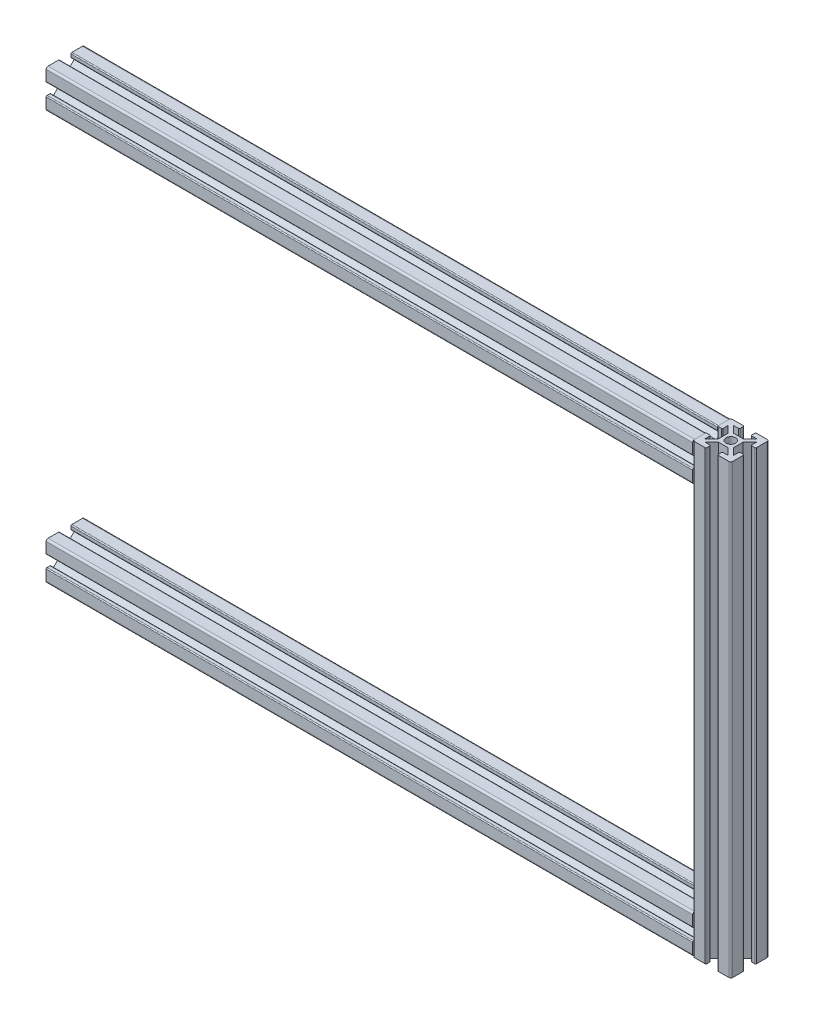
from build123d import *

# Parameters (mm, degrees)
SKETCH1_R                               = 2.5
ALUMINIUM_PROF_ALUMINIUM_PROF_1_DEPTH   = 365.192388155
SKETCH1_ON_SEGMENT_2_R                  = 2.5
ALUMINIUM_PROF_ALUMINIUM_PROF_1_2_DEPTH = 245.384776311
SKETCH1_ON_SEGMENT_3_R                  = 2.5
ALUMINIUM_PROF_ALUMINIUM_PROF_1_3_DEPTH = 365.192388155
BODY_START                              = 61.926406871
BODY_2_RUN_ON_DEPTH                     = 57.269552622
BODY_START_2                            = 183.458369439
BODY_2_RUN_ON_2_DEPTH                   = 57.269552622
SKETCH3_R                               = 2.5
CUT_EXTRUDE1_DEPTH                      = 10


with BuildPart() as part:
    # Sketch1 → Aluminium prof ALUMINIUM PROF(1) (new body)
    with BuildSketch(Plane.YZ):
        with BuildLine():
            Line((-2.5, 4), (2.5, 4))
            Line((2.5, 4), (6.035533906, 7.535533906))
            Line((6.035533906, 7.535533906), (3.535533906, 7.535533906))
            ThreePointArc((3.535533906, 7.535533906), (3.181980515, 7.681980515), (3.035533906, 8.035533906))
            Line((3.035533906, 8.035533906), (3.035533906, 9.535533906))
            ThreePointArc((3.035533906, 9.535533906), (3.181980515, 9.889087297), (3.535533906, 10.035533906))
            Line((3.535533906, 10.035533906), (9.035533906, 10.035533906))
            ThreePointArc((9.035533906, 10.035533906), (9.742640687, 9.742640687), (10.035533906, 9.035533906))
            Line((10.035533906, 9.035533906), (10.035533906, 3.535533906))
            ThreePointArc((10.035533906, 3.535533906), (9.889087297, 3.181980515), (9.535533906, 3.035533906))
            Line((9.535533906, 3.035533906), (8.035533906, 3.035533906))
            ThreePointArc((8.035533906, 3.035533906), (7.681980515, 3.181980515), (7.535533906, 3.535533906))
            Line((7.535533906, 3.535533906), (7.535533906, 6.035533906))
            Line((7.535533906, 6.035533906), (4, 2.5))
            Line((4, 2.5), (4, -2.5))
            Line((4, -2.5), (7.535533906, -6.035533906))
            Line((7.535533906, -6.035533906), (7.535533906, -3.535533906))
            ThreePointArc((7.535533906, -3.535533906), (7.681980515, -3.181980515), (8.035533906, -3.035533906))
            Line((8.035533906, -3.035533906), (9.535533906, -3.035533906))
            ThreePointArc((9.535533906, -3.035533906), (9.889087297, -3.181980515), (10.035533906, -3.535533906))
            Line((10.035533906, -3.535533906), (10.035533906, -9.035533906))
            ThreePointArc((10.035533906, -9.035533906), (9.742640687, -9.742640687), (9.035533906, -10.035533906))
            Line((9.035533906, -10.035533906), (3.535533906, -10.035533906))
            ThreePointArc((3.535533906, -10.035533906), (3.181980515, -9.889087297), (3.035533906, -9.535533906))
            Line((3.035533906, -9.535533906), (3.035533906, -8.035533906))
            ThreePointArc((3.035533906, -8.035533906), (3.181980515, -7.681980515), (3.535533906, -7.535533906))
            Line((3.535533906, -7.535533906), (6.035533906, -7.535533906))
            Line((6.035533906, -7.535533906), (2.5, -4))
            Line((2.5, -4), (-2.5, -4))
            Line((-2.5, -4), (-6.035533906, -7.535533906))
            Line((-6.035533906, -7.535533906), (-3.535533906, -7.535533906))
            ThreePointArc((-3.535533906, -7.535533906), (-3.181980515, -7.681980515), (-3.035533906, -8.035533906))
            Line((-3.035533906, -8.035533906), (-3.035533906, -9.535533906))
            ThreePointArc((-3.035533906, -9.535533906), (-3.181980515, -9.889087297), (-3.535533906, -10.035533906))
            Line((-3.535533906, -10.035533906), (-9.035533906, -10.035533906))
            ThreePointArc((-9.035533906, -10.035533906), (-9.742640687, -9.742640687), (-10.035533906, -9.035533906))
            Line((-10.035533906, -9.035533906), (-10.035533906, -3.535533906))
            ThreePointArc((-10.035533906, -3.535533906), (-9.889087297, -3.181980515), (-9.535533906, -3.035533906))
            Line((-9.535533906, -3.035533906), (-8.035533906, -3.035533906))
            ThreePointArc((-8.035533906, -3.035533906), (-7.681980515, -3.181980515), (-7.535533906, -3.535533906))
            Line((-7.535533906, -3.535533906), (-7.535533906, -6.035533906))
            Line((-7.535533906, -6.035533906), (-4, -2.5))
            Line((-4, -2.5), (-4, 2.5))
            Line((-4, 2.5), (-7.535533906, 6.035533906))
            Line((-7.535533906, 6.035533906), (-7.535533906, 3.535533906))
            ThreePointArc((-7.535533906, 3.535533906), (-7.681980515, 3.181980515), (-8.035533906, 3.035533906))
            Line((-8.035533906, 3.035533906), (-9.535533906, 3.035533906))
            ThreePointArc((-9.535533906, 3.035533906), (-9.889087297, 3.181980515), (-10.035533906, 3.535533906))
            Line((-10.035533906, 3.535533906), (-10.035533906, 9.035533906))
            ThreePointArc((-10.035533906, 9.035533906), (-9.742640687, 9.742640687), (-9.035533906, 10.035533906))
            Line((-9.035533906, 10.035533906), (-3.535533906, 10.035533906))
            ThreePointArc((-3.535533906, 10.035533906), (-3.181980515, 9.889087297), (-3.035533906, 9.535533906))
            Line((-3.035533906, 9.535533906), (-3.035533906, 8.035533906))
            ThreePointArc((-3.035533906, 8.035533906), (-3.181980515, 7.681980515), (-3.535533906, 7.535533906))
            Line((-3.535533906, 7.535533906), (-6.035533906, 7.535533906))
            Line((-6.035533906, 7.535533906), (-2.5, 4))
        make_face()
        Circle(SKETCH1_R, mode=Mode.SUBTRACT)
    extrude(amount=ALUMINIUM_PROF_ALUMINIUM_PROF_1_DEPTH)

    # Aluminium prof ALUMINIUM PROF(1) mitre 1
    split(bisect_by=Plane(origin=(350, 0, 0), x_dir=(-0.707106781, -0.707106781, 0), z_dir=(-0.707106781, 0.707106781, 0)), keep=Keep.TOP)

    # Trim_Extend1 8
    split(bisect_by=Plane(origin=(355.77696345, -107.5, 4.27696345), x_dir=(0, -1, 0), z_dir=(-0.707106781, 0, 0.707106781)), keep=Keep.TOP)

    # Trim_Extend1 10
    split(bisect_by=Plane(origin=(355.77696345, -107.5, -4.27696345), x_dir=(0, -1, 0), z_dir=(-0.707106781, 0, -0.707106781)), keep=Keep.TOP)

    # Trim_Extend1 21
    split(bisect_by=Plane(origin=(339.964466094, -107.5, 6.285533906), x_dir=(0, -1, 0), z_dir=(-1, 0, 0)), keep=Keep.TOP)

    # Sketch3 → Cut-Extrude1 (cut)
    with BuildSketch(Plane(origin=(0, 4, 0), x_dir=(1, 0, 0), z_dir=(0, 1, 0))):
        with Locations(Location((75, 0, 0), (0, 0, 270))):
            Circle(SKETCH3_R)
        with Locations(Location((175, 0, 0), (0, 0, 270))):
            Circle(SKETCH3_R)
        with Locations(Location((264.964466094, 0, 0), (0, 0, 270))):
            Circle(SKETCH3_R)
    extrude(amount=-CUT_EXTRUDE1_DEPTH, mode=Mode.SUBTRACT)


with BuildPart() as body_2:
    # Sketch1 on segment 2 (carried to segment 2) → Aluminium prof ALUMINIUM PROF_1 2 (new body)
    with BuildSketch(Plane(origin=(350, 15.192388155, 0), x_dir=(1, 0, 0), z_dir=(0, -1, 0))):
        with BuildLine():
            Line((-2.5, 4), (2.5, 4))
            Line((2.5, 4), (6.035533906, 7.535533906))
            Line((6.035533906, 7.535533906), (3.535533906, 7.535533906))
            ThreePointArc((3.535533906, 7.535533906), (3.181980515, 7.681980515), (3.035533906, 8.035533906))
            Line((3.035533906, 8.035533906), (3.035533906, 9.535533906))
            ThreePointArc((3.035533906, 9.535533906), (3.181980515, 9.889087297), (3.535533906, 10.035533906))
            Line((3.535533906, 10.035533906), (9.035533906, 10.035533906))
            ThreePointArc((9.035533906, 10.035533906), (9.742640687, 9.742640687), (10.035533906, 9.035533906))
            Line((10.035533906, 9.035533906), (10.035533906, 3.535533906))
            ThreePointArc((10.035533906, 3.535533906), (9.889087297, 3.181980515), (9.535533906, 3.035533906))
            Line((9.535533906, 3.035533906), (8.035533906, 3.035533906))
            ThreePointArc((8.035533906, 3.035533906), (7.681980515, 3.181980515), (7.535533906, 3.535533906))
            Line((7.535533906, 3.535533906), (7.535533906, 6.035533906))
            Line((7.535533906, 6.035533906), (4, 2.5))
            Line((4, 2.5), (4, -2.5))
            Line((4, -2.5), (7.535533906, -6.035533906))
            Line((7.535533906, -6.035533906), (7.535533906, -3.535533906))
            ThreePointArc((7.535533906, -3.535533906), (7.681980515, -3.181980515), (8.035533906, -3.035533906))
            Line((8.035533906, -3.035533906), (9.535533906, -3.035533906))
            ThreePointArc((9.535533906, -3.035533906), (9.889087297, -3.181980515), (10.035533906, -3.535533906))
            Line((10.035533906, -3.535533906), (10.035533906, -9.035533906))
            ThreePointArc((10.035533906, -9.035533906), (9.742640687, -9.742640687), (9.035533906, -10.035533906))
            Line((9.035533906, -10.035533906), (3.535533906, -10.035533906))
            ThreePointArc((3.535533906, -10.035533906), (3.181980515, -9.889087297), (3.035533906, -9.535533906))
            Line((3.035533906, -9.535533906), (3.035533906, -8.035533906))
            ThreePointArc((3.035533906, -8.035533906), (3.181980515, -7.681980515), (3.535533906, -7.535533906))
            Line((3.535533906, -7.535533906), (6.035533906, -7.535533906))
            Line((6.035533906, -7.535533906), (2.5, -4))
            Line((2.5, -4), (-2.5, -4))
            Line((-2.5, -4), (-6.035533906, -7.535533906))
            Line((-6.035533906, -7.535533906), (-3.535533906, -7.535533906))
            ThreePointArc((-3.535533906, -7.535533906), (-3.181980515, -7.681980515), (-3.035533906, -8.035533906))
            Line((-3.035533906, -8.035533906), (-3.035533906, -9.535533906))
            ThreePointArc((-3.035533906, -9.535533906), (-3.181980515, -9.889087297), (-3.535533906, -10.035533906))
            Line((-3.535533906, -10.035533906), (-9.035533906, -10.035533906))
            ThreePointArc((-9.035533906, -10.035533906), (-9.742640687, -9.742640687), (-10.035533906, -9.035533906))
            Line((-10.035533906, -9.035533906), (-10.035533906, -3.535533906))
            ThreePointArc((-10.035533906, -3.535533906), (-9.889087297, -3.181980515), (-9.535533906, -3.035533906))
            Line((-9.535533906, -3.035533906), (-8.035533906, -3.035533906))
            ThreePointArc((-8.035533906, -3.035533906), (-7.681980515, -3.181980515), (-7.535533906, -3.535533906))
            Line((-7.535533906, -3.535533906), (-7.535533906, -6.035533906))
            Line((-7.535533906, -6.035533906), (-4, -2.5))
            Line((-4, -2.5), (-4, 2.5))
            Line((-4, 2.5), (-7.535533906, 6.035533906))
            Line((-7.535533906, 6.035533906), (-7.535533906, 3.535533906))
            ThreePointArc((-7.535533906, 3.535533906), (-7.681980515, 3.181980515), (-8.035533906, 3.035533906))
            Line((-8.035533906, 3.035533906), (-9.535533906, 3.035533906))
            ThreePointArc((-9.535533906, 3.035533906), (-9.889087297, 3.181980515), (-10.035533906, 3.535533906))
            Line((-10.035533906, 3.535533906), (-10.035533906, 9.035533906))
            ThreePointArc((-10.035533906, 9.035533906), (-9.742640687, 9.742640687), (-9.035533906, 10.035533906))
            Line((-9.035533906, 10.035533906), (-3.535533906, 10.035533906))
            ThreePointArc((-3.535533906, 10.035533906), (-3.181980515, 9.889087297), (-3.035533906, 9.535533906))
            Line((-3.035533906, 9.535533906), (-3.035533906, 8.035533906))
            ThreePointArc((-3.035533906, 8.035533906), (-3.181980515, 7.681980515), (-3.535533906, 7.535533906))
            Line((-3.535533906, 7.535533906), (-6.035533906, 7.535533906))
            Line((-6.035533906, 7.535533906), (-2.5, 4))
        make_face()
        Circle(SKETCH1_ON_SEGMENT_2_R, mode=Mode.SUBTRACT)
    extrude(amount=ALUMINIUM_PROF_ALUMINIUM_PROF_1_2_DEPTH)

    # Aluminium prof ALUMINIUM PROF_1 2 mitre
    split(bisect_by=Plane(origin=(350, 0, 0), x_dir=(0.707106781, 0.707106781, 0), z_dir=(0.707106781, -0.707106781, 0)), keep=Keep.TOP)

    # Aluminium prof ALUMINIUM PROF_1 2 mi 2
    split(bisect_by=Plane(origin=(350, -215, 0), x_dir=(-0.707106781, 0.707106781, 0), z_dir=(0.707106781, 0.707106781, 0)), keep=Keep.TOP)

    # body 2 cut square before the run-on
    split(bisect_by=Plane(origin=(350, -46.734018716, 0), x_dir=(1, 0, 0), z_dir=(0, -1, 0)), keep=Keep.TOP)

    # Sketch1 on segment 2 (carried to segment 2) → body 2 run on (add)
    with BuildSketch(Plane(origin=(350, 15.192388155, 0), x_dir=(1, 0, 0), z_dir=(0, -1, 0)).offset(BODY_START)):
        with BuildLine():
            Line((-2.5, 4), (2.5, 4))
            Line((2.5, 4), (6.035533906, 7.535533906))
            Line((6.035533906, 7.535533906), (3.535533906, 7.535533906))
            ThreePointArc((3.535533906, 7.535533906), (3.181980515, 7.681980515), (3.035533906, 8.035533906))
            Line((3.035533906, 8.035533906), (3.035533906, 9.535533906))
            ThreePointArc((3.035533906, 9.535533906), (3.181980515, 9.889087297), (3.535533906, 10.035533906))
            Line((3.535533906, 10.035533906), (9.035533906, 10.035533906))
            ThreePointArc((9.035533906, 10.035533906), (9.742640687, 9.742640687), (10.035533906, 9.035533906))
            Line((10.035533906, 9.035533906), (10.035533906, 3.535533906))
            ThreePointArc((10.035533906, 3.535533906), (9.889087297, 3.181980515), (9.535533906, 3.035533906))
            Line((9.535533906, 3.035533906), (8.035533906, 3.035533906))
            ThreePointArc((8.035533906, 3.035533906), (7.681980515, 3.181980515), (7.535533906, 3.535533906))
            Line((7.535533906, 3.535533906), (7.535533906, 6.035533906))
            Line((7.535533906, 6.035533906), (4, 2.5))
            Line((4, 2.5), (4, -2.5))
            Line((4, -2.5), (7.535533906, -6.035533906))
            Line((7.535533906, -6.035533906), (7.535533906, -3.535533906))
            ThreePointArc((7.535533906, -3.535533906), (7.681980515, -3.181980515), (8.035533906, -3.035533906))
            Line((8.035533906, -3.035533906), (9.535533906, -3.035533906))
            ThreePointArc((9.535533906, -3.035533906), (9.889087297, -3.181980515), (10.035533906, -3.535533906))
            Line((10.035533906, -3.535533906), (10.035533906, -9.035533906))
            ThreePointArc((10.035533906, -9.035533906), (9.742640687, -9.742640687), (9.035533906, -10.035533906))
            Line((9.035533906, -10.035533906), (3.535533906, -10.035533906))
            ThreePointArc((3.535533906, -10.035533906), (3.181980515, -9.889087297), (3.035533906, -9.535533906))
            Line((3.035533906, -9.535533906), (3.035533906, -8.035533906))
            ThreePointArc((3.035533906, -8.035533906), (3.181980515, -7.681980515), (3.535533906, -7.535533906))
            Line((3.535533906, -7.535533906), (6.035533906, -7.535533906))
            Line((6.035533906, -7.535533906), (2.5, -4))
            Line((2.5, -4), (-2.5, -4))
            Line((-2.5, -4), (-6.035533906, -7.535533906))
            Line((-6.035533906, -7.535533906), (-3.535533906, -7.535533906))
            ThreePointArc((-3.535533906, -7.535533906), (-3.181980515, -7.681980515), (-3.035533906, -8.035533906))
            Line((-3.035533906, -8.035533906), (-3.035533906, -9.535533906))
            ThreePointArc((-3.035533906, -9.535533906), (-3.181980515, -9.889087297), (-3.535533906, -10.035533906))
            Line((-3.535533906, -10.035533906), (-9.035533906, -10.035533906))
            ThreePointArc((-9.035533906, -10.035533906), (-9.742640687, -9.742640687), (-10.035533906, -9.035533906))
            Line((-10.035533906, -9.035533906), (-10.035533906, -3.535533906))
            ThreePointArc((-10.035533906, -3.535533906), (-9.889087297, -3.181980515), (-9.535533906, -3.035533906))
            Line((-9.535533906, -3.035533906), (-8.035533906, -3.035533906))
            ThreePointArc((-8.035533906, -3.035533906), (-7.681980515, -3.181980515), (-7.535533906, -3.535533906))
            Line((-7.535533906, -3.535533906), (-7.535533906, -6.035533906))
            Line((-7.535533906, -6.035533906), (-4, -2.5))
            Line((-4, -2.5), (-4, 2.5))
            Line((-4, 2.5), (-7.535533906, 6.035533906))
            Line((-7.535533906, 6.035533906), (-7.535533906, 3.535533906))
            ThreePointArc((-7.535533906, 3.535533906), (-7.681980515, 3.181980515), (-8.035533906, 3.035533906))
            Line((-8.035533906, 3.035533906), (-9.535533906, 3.035533906))
            ThreePointArc((-9.535533906, 3.035533906), (-9.889087297, 3.181980515), (-10.035533906, 3.535533906))
            Line((-10.035533906, 3.535533906), (-10.035533906, 9.035533906))
            ThreePointArc((-10.035533906, 9.035533906), (-9.742640687, 9.742640687), (-9.035533906, 10.035533906))
            Line((-9.035533906, 10.035533906), (-3.535533906, 10.035533906))
            ThreePointArc((-3.535533906, 10.035533906), (-3.181980515, 9.889087297), (-3.035533906, 9.535533906))
            Line((-3.035533906, 9.535533906), (-3.035533906, 8.035533906))
            ThreePointArc((-3.035533906, 8.035533906), (-3.181980515, 7.681980515), (-3.535533906, 7.535533906))
            Line((-3.535533906, 7.535533906), (-6.035533906, 7.535533906))
            Line((-6.035533906, 7.535533906), (-2.5, 4))
        make_face()
        Circle(SKETCH1_ON_SEGMENT_2_R, mode=Mode.SUBTRACT)
    extrude(amount=-BODY_2_RUN_ON_DEPTH)

    # Trim_Extend1 2
    split(bisect_by=Plane(origin=(180.017766953, 10.035533906, 6.285533906), x_dir=(1, 0, 0), z_dir=(0, -1, 0)), keep=Keep.TOP)

    # body 2 cut square before the run-on
    split(bisect_by=Plane(origin=(350, -168.265981284, 0), x_dir=(-1, 0, 0), z_dir=(0, 1, 0)), keep=Keep.TOP)

    # Sketch1 on segment 2 (carried to segment 2) → body 2 run on 2 (add)
    with BuildSketch(Plane(origin=(350, 15.192388155, 0), x_dir=(1, 0, 0), z_dir=(0, -1, 0)).offset(BODY_START_2)):
        with BuildLine():
            Line((-2.5, 4), (2.5, 4))
            Line((2.5, 4), (6.035533906, 7.535533906))
            Line((6.035533906, 7.535533906), (3.535533906, 7.535533906))
            ThreePointArc((3.535533906, 7.535533906), (3.181980515, 7.681980515), (3.035533906, 8.035533906))
            Line((3.035533906, 8.035533906), (3.035533906, 9.535533906))
            ThreePointArc((3.035533906, 9.535533906), (3.181980515, 9.889087297), (3.535533906, 10.035533906))
            Line((3.535533906, 10.035533906), (9.035533906, 10.035533906))
            ThreePointArc((9.035533906, 10.035533906), (9.742640687, 9.742640687), (10.035533906, 9.035533906))
            Line((10.035533906, 9.035533906), (10.035533906, 3.535533906))
            ThreePointArc((10.035533906, 3.535533906), (9.889087297, 3.181980515), (9.535533906, 3.035533906))
            Line((9.535533906, 3.035533906), (8.035533906, 3.035533906))
            ThreePointArc((8.035533906, 3.035533906), (7.681980515, 3.181980515), (7.535533906, 3.535533906))
            Line((7.535533906, 3.535533906), (7.535533906, 6.035533906))
            Line((7.535533906, 6.035533906), (4, 2.5))
            Line((4, 2.5), (4, -2.5))
            Line((4, -2.5), (7.535533906, -6.035533906))
            Line((7.535533906, -6.035533906), (7.535533906, -3.535533906))
            ThreePointArc((7.535533906, -3.535533906), (7.681980515, -3.181980515), (8.035533906, -3.035533906))
            Line((8.035533906, -3.035533906), (9.535533906, -3.035533906))
            ThreePointArc((9.535533906, -3.035533906), (9.889087297, -3.181980515), (10.035533906, -3.535533906))
            Line((10.035533906, -3.535533906), (10.035533906, -9.035533906))
            ThreePointArc((10.035533906, -9.035533906), (9.742640687, -9.742640687), (9.035533906, -10.035533906))
            Line((9.035533906, -10.035533906), (3.535533906, -10.035533906))
            ThreePointArc((3.535533906, -10.035533906), (3.181980515, -9.889087297), (3.035533906, -9.535533906))
            Line((3.035533906, -9.535533906), (3.035533906, -8.035533906))
            ThreePointArc((3.035533906, -8.035533906), (3.181980515, -7.681980515), (3.535533906, -7.535533906))
            Line((3.535533906, -7.535533906), (6.035533906, -7.535533906))
            Line((6.035533906, -7.535533906), (2.5, -4))
            Line((2.5, -4), (-2.5, -4))
            Line((-2.5, -4), (-6.035533906, -7.535533906))
            Line((-6.035533906, -7.535533906), (-3.535533906, -7.535533906))
            ThreePointArc((-3.535533906, -7.535533906), (-3.181980515, -7.681980515), (-3.035533906, -8.035533906))
            Line((-3.035533906, -8.035533906), (-3.035533906, -9.535533906))
            ThreePointArc((-3.035533906, -9.535533906), (-3.181980515, -9.889087297), (-3.535533906, -10.035533906))
            Line((-3.535533906, -10.035533906), (-9.035533906, -10.035533906))
            ThreePointArc((-9.035533906, -10.035533906), (-9.742640687, -9.742640687), (-10.035533906, -9.035533906))
            Line((-10.035533906, -9.035533906), (-10.035533906, -3.535533906))
            ThreePointArc((-10.035533906, -3.535533906), (-9.889087297, -3.181980515), (-9.535533906, -3.035533906))
            Line((-9.535533906, -3.035533906), (-8.035533906, -3.035533906))
            ThreePointArc((-8.035533906, -3.035533906), (-7.681980515, -3.181980515), (-7.535533906, -3.535533906))
            Line((-7.535533906, -3.535533906), (-7.535533906, -6.035533906))
            Line((-7.535533906, -6.035533906), (-4, -2.5))
            Line((-4, -2.5), (-4, 2.5))
            Line((-4, 2.5), (-7.535533906, 6.035533906))
            Line((-7.535533906, 6.035533906), (-7.535533906, 3.535533906))
            ThreePointArc((-7.535533906, 3.535533906), (-7.681980515, 3.181980515), (-8.035533906, 3.035533906))
            Line((-8.035533906, 3.035533906), (-9.535533906, 3.035533906))
            ThreePointArc((-9.535533906, 3.035533906), (-9.889087297, 3.181980515), (-10.035533906, 3.535533906))
            Line((-10.035533906, 3.535533906), (-10.035533906, 9.035533906))
            ThreePointArc((-10.035533906, 9.035533906), (-9.742640687, 9.742640687), (-9.035533906, 10.035533906))
            Line((-9.035533906, 10.035533906), (-3.535533906, 10.035533906))
            ThreePointArc((-3.535533906, 10.035533906), (-3.181980515, 9.889087297), (-3.035533906, 9.535533906))
            Line((-3.035533906, 9.535533906), (-3.035533906, 8.035533906))
            ThreePointArc((-3.035533906, 8.035533906), (-3.181980515, 7.681980515), (-3.535533906, 7.535533906))
            Line((-3.535533906, 7.535533906), (-6.035533906, 7.535533906))
            Line((-6.035533906, 7.535533906), (-2.5, 4))
        make_face()
        Circle(SKETCH1_ON_SEGMENT_2_R, mode=Mode.SUBTRACT)
    extrude(amount=BODY_2_RUN_ON_2_DEPTH)

    # Trim_Extend2 2
    split(bisect_by=Plane(origin=(180.017766953, -225.035533906, 6.285533906), x_dir=(-1, 0, 0), z_dir=(0, 1, 0)), keep=Keep.TOP)


with BuildPart() as body_3:
    # Sketch1 on segment 3 (carried to segment 3) → Aluminium prof ALUMINIUM PROF_1 3 (new body)
    with BuildSketch(Plane(origin=(365.192388155, -215, 0), x_dir=(0, -1, 0), z_dir=(-1, 0, 0))):
        with BuildLine():
            Line((-2.5, 4), (2.5, 4))
            Line((2.5, 4), (6.035533906, 7.535533906))
            Line((6.035533906, 7.535533906), (3.535533906, 7.535533906))
            ThreePointArc((3.535533906, 7.535533906), (3.181980515, 7.681980515), (3.035533906, 8.035533906))
            Line((3.035533906, 8.035533906), (3.035533906, 9.535533906))
            ThreePointArc((3.035533906, 9.535533906), (3.181980515, 9.889087297), (3.535533906, 10.035533906))
            Line((3.535533906, 10.035533906), (9.035533906, 10.035533906))
            ThreePointArc((9.035533906, 10.035533906), (9.742640687, 9.742640687), (10.035533906, 9.035533906))
            Line((10.035533906, 9.035533906), (10.035533906, 3.535533906))
            ThreePointArc((10.035533906, 3.535533906), (9.889087297, 3.181980515), (9.535533906, 3.035533906))
            Line((9.535533906, 3.035533906), (8.035533906, 3.035533906))
            ThreePointArc((8.035533906, 3.035533906), (7.681980515, 3.181980515), (7.535533906, 3.535533906))
            Line((7.535533906, 3.535533906), (7.535533906, 6.035533906))
            Line((7.535533906, 6.035533906), (4, 2.5))
            Line((4, 2.5), (4, -2.5))
            Line((4, -2.5), (7.535533906, -6.035533906))
            Line((7.535533906, -6.035533906), (7.535533906, -3.535533906))
            ThreePointArc((7.535533906, -3.535533906), (7.681980515, -3.181980515), (8.035533906, -3.035533906))
            Line((8.035533906, -3.035533906), (9.535533906, -3.035533906))
            ThreePointArc((9.535533906, -3.035533906), (9.889087297, -3.181980515), (10.035533906, -3.535533906))
            Line((10.035533906, -3.535533906), (10.035533906, -9.035533906))
            ThreePointArc((10.035533906, -9.035533906), (9.742640687, -9.742640687), (9.035533906, -10.035533906))
            Line((9.035533906, -10.035533906), (3.535533906, -10.035533906))
            ThreePointArc((3.535533906, -10.035533906), (3.181980515, -9.889087297), (3.035533906, -9.535533906))
            Line((3.035533906, -9.535533906), (3.035533906, -8.035533906))
            ThreePointArc((3.035533906, -8.035533906), (3.181980515, -7.681980515), (3.535533906, -7.535533906))
            Line((3.535533906, -7.535533906), (6.035533906, -7.535533906))
            Line((6.035533906, -7.535533906), (2.5, -4))
            Line((2.5, -4), (-2.5, -4))
            Line((-2.5, -4), (-6.035533906, -7.535533906))
            Line((-6.035533906, -7.535533906), (-3.535533906, -7.535533906))
            ThreePointArc((-3.535533906, -7.535533906), (-3.181980515, -7.681980515), (-3.035533906, -8.035533906))
            Line((-3.035533906, -8.035533906), (-3.035533906, -9.535533906))
            ThreePointArc((-3.035533906, -9.535533906), (-3.181980515, -9.889087297), (-3.535533906, -10.035533906))
            Line((-3.535533906, -10.035533906), (-9.035533906, -10.035533906))
            ThreePointArc((-9.035533906, -10.035533906), (-9.742640687, -9.742640687), (-10.035533906, -9.035533906))
            Line((-10.035533906, -9.035533906), (-10.035533906, -3.535533906))
            ThreePointArc((-10.035533906, -3.535533906), (-9.889087297, -3.181980515), (-9.535533906, -3.035533906))
            Line((-9.535533906, -3.035533906), (-8.035533906, -3.035533906))
            ThreePointArc((-8.035533906, -3.035533906), (-7.681980515, -3.181980515), (-7.535533906, -3.535533906))
            Line((-7.535533906, -3.535533906), (-7.535533906, -6.035533906))
            Line((-7.535533906, -6.035533906), (-4, -2.5))
            Line((-4, -2.5), (-4, 2.5))
            Line((-4, 2.5), (-7.535533906, 6.035533906))
            Line((-7.535533906, 6.035533906), (-7.535533906, 3.535533906))
            ThreePointArc((-7.535533906, 3.535533906), (-7.681980515, 3.181980515), (-8.035533906, 3.035533906))
            Line((-8.035533906, 3.035533906), (-9.535533906, 3.035533906))
            ThreePointArc((-9.535533906, 3.035533906), (-9.889087297, 3.181980515), (-10.035533906, 3.535533906))
            Line((-10.035533906, 3.535533906), (-10.035533906, 9.035533906))
            ThreePointArc((-10.035533906, 9.035533906), (-9.742640687, 9.742640687), (-9.035533906, 10.035533906))
            Line((-9.035533906, 10.035533906), (-3.535533906, 10.035533906))
            ThreePointArc((-3.535533906, 10.035533906), (-3.181980515, 9.889087297), (-3.035533906, 9.535533906))
            Line((-3.035533906, 9.535533906), (-3.035533906, 8.035533906))
            ThreePointArc((-3.035533906, 8.035533906), (-3.181980515, 7.681980515), (-3.535533906, 7.535533906))
            Line((-3.535533906, 7.535533906), (-6.035533906, 7.535533906))
            Line((-6.035533906, 7.535533906), (-2.5, 4))
        make_face()
        Circle(SKETCH1_ON_SEGMENT_3_R, mode=Mode.SUBTRACT)
    extrude(amount=ALUMINIUM_PROF_ALUMINIUM_PROF_1_3_DEPTH)

    # Aluminium prof ALUMINIUM PROF_1 3 mitre
    split(bisect_by=Plane(origin=(350, -215, 0), x_dir=(0.707106781, -0.707106781, 0), z_dir=(-0.707106781, -0.707106781, 0)), keep=Keep.TOP)

    # Trim_Extend2 7
    split(bisect_by=Plane(origin=(339.964466094, -97.464466094, 6.285533906), x_dir=(0, -1, 0), z_dir=(-1, 0, 0)), keep=Keep.TOP)


solid = Compound([part.part, body_2.part, body_3.part])
